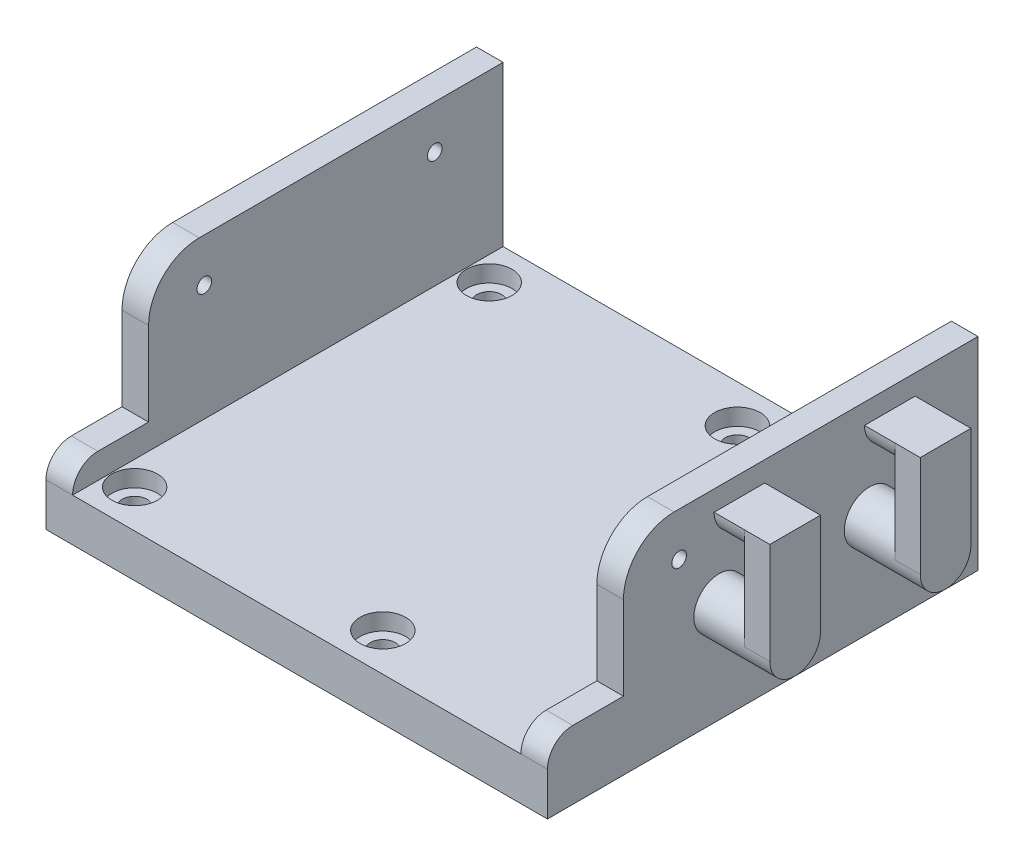
from build123d import *

# Parameters (mm, degrees)
SKETCH1_W            = 99
SKETCH1_H            = 85
BOSS_EXTRUDE1_DEPTH  = 40
SKETCH2_W            = 88.5
SKETCH2_H            = 85
CUT_EXTRUDE1_DEPTH   = 31.5
SKETCH5_R            = 4.5
CUT_EXTRUDE3_DEPTH   = 3.3
SKETCH6_R            = 2.45
CUT_EXTRUDE4_DEPTH   = 5.2
SKETCH16_R           = 1.45
CUT_EXTRUDE6_DEPTH   = 93.75
SKETCH17_R           = 5
BOSS_EXTRUDE2_DEPTH  = 15
SKETCH18_W           = 10
SKETCH18_H           = 20
BOSS_EXTRUDE3_DEPTH  = 5
BOSS_EXTRUDE4_DEPTH  = 11
SKETCH20_W           = 15
SKETCH20_H           = 26.5
CUT_EXTRUDE7_DEPTH   = 93.75
FILLET1_R            = 10
FILLET2_R            = 5
FILLET1_OF_MIRROR3_R = 10
FILLET2_OF_MIRROR3_R = 5
SKETCH21_W           = 10
SKETCH21_H           = 20
BOSS_EXTRUDE5_DEPTH  = 5
BOSS_EXTRUDE7_DEPTH  = 11


with BuildPart() as part:
    # Sketch1 → Boss-Extrude1 (new body)
    with BuildSketch(Plane(origin=(0, 0, 0), x_dir=(1, 0, 0), z_dir=(0, 1, 0))):
        Rectangle(SKETCH1_W, SKETCH1_H)
    extrude(amount=BOSS_EXTRUDE1_DEPTH)

    # Sketch2 → Cut-Extrude1 (cut)
    with BuildSketch(Plane(origin=(0, 40, 0), x_dir=(1, 0, 0), z_dir=(0, 1, 0))):
        Rectangle(SKETCH2_W, SKETCH2_H)
    extrude(amount=-CUT_EXTRUDE1_DEPTH, mode=Mode.SUBTRACT)

    # Sketch5 → Cut-Extrude3 (cut)
    with BuildSketch(Plane(origin=(0, 8.5, 0), x_dir=(1, 0, 0), z_dir=(0, 1, 0))):
        with Locations((-39.5, 35)):
            Circle(SKETCH5_R)
        with Locations((9.5, 35)):
            Circle(SKETCH5_R)
        with Locations((-39.5, -35)):
            Circle(SKETCH5_R)
        with Locations((9.5, -35)):
            Circle(SKETCH5_R)
    extrude(amount=-CUT_EXTRUDE3_DEPTH, mode=Mode.SUBTRACT)

    # Sketch6 → Cut-Extrude4 (cut)
    with BuildSketch(Plane(origin=(0, 5.2, 0), x_dir=(1, 0, 0), z_dir=(0, 1, 0))):
        with Locations((-39.5, 35)):
            Circle(SKETCH6_R)
        with Locations((9.5, 35)):
            Circle(SKETCH6_R)
        with Locations((9.5, -35)):
            Circle(SKETCH6_R)
        with Locations((-39.5, -35)):
            Circle(SKETCH6_R)
    extrude(amount=-CUT_EXTRUDE4_DEPTH, mode=Mode.SUBTRACT)

    # Sketch16 → Cut-Extrude6 (cut)
    with BuildSketch(Plane.ZY.offset(49.5)):
        with Locations((-29, 31.4)):
            Circle(SKETCH16_R)
        with Locations((16.5, 31.4)):
            Circle(SKETCH16_R)
    cut_extrude6 = extrude(amount=-CUT_EXTRUDE6_DEPTH, mode=Mode.SUBTRACT)

    # Mirror1: Cut-Extrude6 across plane
    add(cut_extrude6.mirror(Plane(origin=(0, 0, 0), x_dir=(0, 0, 1), z_dir=(1, 0, 0))), mode=Mode.SUBTRACT)

    # Sketch17 → Boss-Extrude2 (add)
    with BuildSketch(Plane(origin=(49.5, 0, 0), x_dir=(0, 0, -1), z_dir=(1, 0, 0))):
        with Locations((-8.6, 20)):
            Circle(SKETCH17_R)
        with Locations((21.1, 20)):
            Circle(SKETCH17_R)
    extrude(amount=BOSS_EXTRUDE2_DEPTH)

    # Sketch18 → Boss-Extrude3 (add)
    with BuildSketch(Plane(origin=(64.5, 0, 0), x_dir=(0, 0, -1), z_dir=(1, 0, 0))):
        with Locations((-8.6, 30)):
            Rectangle(SKETCH18_W, SKETCH18_H)
    extrude(amount=-BOSS_EXTRUDE3_DEPTH)

    # Sketch19 → Boss-Extrude4 (add)
    with BuildSketch(Plane(origin=(64.5, 0, 0), x_dir=(0, 0, -1), z_dir=(1, 0, 0))):
        with BuildLine():
            Line((-13.6, 40), (-3.6, 40))
            ThreePointArc((-3.6, 40), (-8.6, 35), (-13.6, 40))
        make_face()
    extrude(amount=-BOSS_EXTRUDE4_DEPTH)

    # Sketch20 → Cut-Extrude7 (cut)
    with BuildSketch(Plane.ZY.offset(49.5)):
        with Locations((35, 26.75)):
            Rectangle(SKETCH20_W, SKETCH20_H)
    cut_extrude7 = extrude(amount=-CUT_EXTRUDE7_DEPTH, mode=Mode.SUBTRACT)

    # Fillet1
    fillet1_edges = [part.edges().sort_by_distance(p)[0] for p in [
        (-46.875, 40, 27.5),
    ]]
    fillet(fillet1_edges, radius=FILLET1_R)

    # Fillet2
    fillet2_edges = [part.edges().sort_by_distance(p)[0] for p in [
        (-46.875, 13.5, 42.5),
    ]]
    fillet(fillet2_edges, radius=FILLET2_R)

    # Mirror3: Cut-Extrude7 across plane
    add(cut_extrude7.mirror(Plane(origin=(0, 0, 0), x_dir=(0, 0, 1), z_dir=(1, 0, 0))), mode=Mode.SUBTRACT)

    # Fillet1 of Mirror3
    fillet1_of_mirror3_edges = [part.edges().sort_by_distance(p)[0] for p in [
        (46.875, 40, 27.5),
    ]]
    fillet(fillet1_of_mirror3_edges, radius=FILLET1_OF_MIRROR3_R)

    # Fillet2 of Mirror3
    fillet2_of_mirror3_edges = [part.edges().sort_by_distance(p)[0] for p in [
        (46.875, 13.5, 42.5),
    ]]
    fillet(fillet2_of_mirror3_edges, radius=FILLET2_OF_MIRROR3_R)

    # Sketch21 → Boss-Extrude5 (add)
    with BuildSketch(Plane(origin=(64.5, 0, 0), x_dir=(0, 0, -1), z_dir=(1, 0, 0))):
        with Locations((21.1, 30)):
            Rectangle(SKETCH21_W, SKETCH21_H)
    extrude(amount=-BOSS_EXTRUDE5_DEPTH)

    # Sketch23 → Boss-Extrude7 (add)
    with BuildSketch(Plane(origin=(64.5, 0, 0), x_dir=(0, 0, -1), z_dir=(1, 0, 0))):
        with BuildLine():
            Line((16.1, 40), (26.1, 40))
            ThreePointArc((26.1, 40), (21.1, 35), (16.1, 40))
        make_face()
    extrude(amount=-BOSS_EXTRUDE7_DEPTH)


solid = part.part
